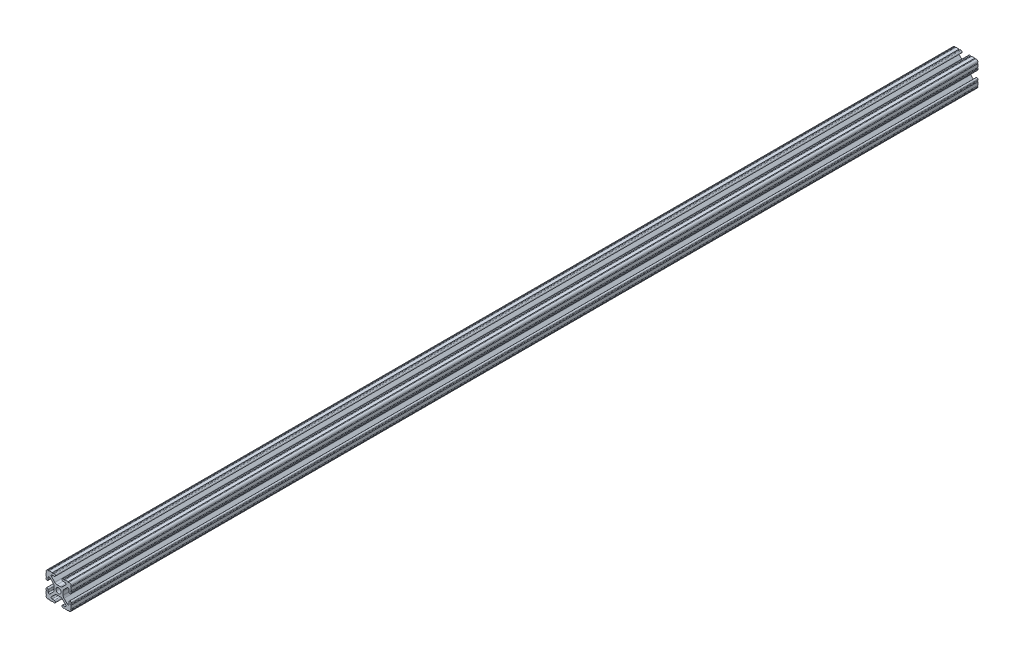
from build123d import *

# Parameters (mm, degrees)
SKETCH1_R           = 2.6035
BOSS_EXTRUDE1_DEPTH = 914.4


with BuildPart() as part:
    # Sketch1 → Boss-Extrude1 (new body)
    with BuildSketch(Plane.XY):
        with BuildLine():
            Line((-12.7, -6.3330836), (-12.7, -9.5504))
            ThreePointArc((-12.7, -9.5504), (-12.192000006, -10.058323491), (-12.699846982, -10.566399977))
            ThreePointArc((-12.699846982, -10.566399977), (-12.082522516, -12.082522516), (-10.566399977, -12.699846982))
            ThreePointArc((-10.566399977, -12.699846982), (-10.058323491, -12.192000006), (-9.5504, -12.7))
            Line((-9.5504, -12.7), (-6.3330836, -12.7))
            ThreePointArc((-6.3330836, -12.7), (-5.8250836, -12.192), (-5.3170836, -12.7))
            Line((-5.3170836, -12.7), (-4.343399971, -12.7))
            ThreePointArc((-4.343399971, -12.7), (-3.238499971, -11.5951), (-4.343399971, -10.4902))
            Line((-4.343399971, -10.4902), (-6.474794456, -10.4902))
            ThreePointArc((-6.474794456, -10.4902), (-7.413456061, -9.863006367), (-7.193214945, -8.75577951))
            Line((-7.193214945, -8.75577951), (-3.863171405, -5.42573597))
            ThreePointArc((-3.863171405, -5.42573597), (-2.833127272, -4.737482484), (-1.618107374, -4.4958))
            Line((-1.618107374, -4.4958), (1.618107374, -4.4958))
            ThreePointArc((1.618107374, -4.4958), (2.833127272, -4.737482484), (3.863171405, -5.42573597))
            Line((3.863171405, -5.42573597), (7.193214945, -8.75577951))
            ThreePointArc((7.193214945, -8.75577951), (7.413456061, -9.863006367), (6.474794456, -10.4902))
            Line((6.474794456, -10.4902), (4.3434, -10.4902))
            ThreePointArc((4.3434, -10.4902), (3.2385, -11.5951), (4.3434, -12.7))
            Line((4.3434, -12.7), (5.3170836, -12.7))
            ThreePointArc((5.3170836, -12.7), (5.8250836, -12.192), (6.3330836, -12.7))
            Line((6.3330836, -12.7), (9.5504, -12.7))
            ThreePointArc((9.5504, -12.7), (10.058323491, -12.192000006), (10.566399977, -12.699846982))
            ThreePointArc((10.566399977, -12.699846982), (12.082522516, -12.082522516), (12.699846982, -10.566399977))
            ThreePointArc((12.699846982, -10.566399977), (12.192000006, -10.058323491), (12.7, -9.5504))
            Line((12.7, -9.5504), (12.7, -6.3330836))
            ThreePointArc((12.7, -6.3330836), (12.192, -5.8250836), (12.7, -5.3170836))
            Line((12.7, -5.3170836), (12.7, -4.343399971))
            ThreePointArc((12.7, -4.343399971), (11.5951, -3.238499971), (10.4902, -4.343399971))
            Line((10.4902, -4.343399971), (10.4902, -6.474794456))
            ThreePointArc((10.4902, -6.474794456), (9.863006367, -7.413456061), (8.75577951, -7.193214945))
            Line((8.75577951, -7.193214945), (5.42573597, -3.863171405))
            ThreePointArc((5.42573597, -3.863171405), (4.737482484, -2.833127272), (4.4958, -1.618107374))
            Line((4.4958, -1.618107374), (4.4958, 1.618107374))
            ThreePointArc((4.4958, 1.618107374), (4.737482484, 2.833127272), (5.42573597, 3.863171405))
            Line((5.42573597, 3.863171405), (8.75577951, 7.193214945))
            ThreePointArc((8.75577951, 7.193214945), (9.863006367, 7.413456061), (10.4902, 6.474794456))
            Line((10.4902, 6.474794456), (10.4902, 4.3434))
            ThreePointArc((10.4902, 4.3434), (11.5951, 3.2385), (12.7, 4.3434))
            Line((12.7, 4.3434), (12.7, 5.3170836))
            ThreePointArc((12.7, 5.3170836), (12.192, 5.8250836), (12.7, 6.3330836))
            Line((12.7, 6.3330836), (12.7, 9.5504))
            ThreePointArc((12.7, 9.5504), (12.192000006, 10.058323491), (12.699846982, 10.566399977))
            ThreePointArc((12.699846982, 10.566399977), (12.082522516, 12.082522516), (10.566399977, 12.699846982))
            ThreePointArc((10.566399977, 12.699846982), (10.058323491, 12.192000006), (9.5504, 12.7))
            Line((9.5504, 12.7), (6.3330836, 12.7))
            ThreePointArc((6.3330836, 12.7), (5.8250836, 12.192), (5.3170836, 12.7))
            Line((5.3170836, 12.7), (4.343399971, 12.7))
            ThreePointArc((4.343399971, 12.7), (3.238499971, 11.5951), (4.343399971, 10.4902))
            Line((4.343399971, 10.4902), (6.474794456, 10.4902))
            ThreePointArc((6.474794456, 10.4902), (7.413456061, 9.863006367), (7.193214945, 8.75577951))
            Line((7.193214945, 8.75577951), (3.863171405, 5.42573597))
            ThreePointArc((3.863171405, 5.42573597), (2.833127272, 4.737482484), (1.618107374, 4.4958))
            Line((1.618107374, 4.4958), (-1.618107374, 4.4958))
            ThreePointArc((-1.618107374, 4.4958), (-2.833127272, 4.737482484), (-3.863171405, 5.42573597))
            Line((-3.863171405, 5.42573597), (-7.193214945, 8.75577951))
            ThreePointArc((-7.193214945, 8.75577951), (-7.413456061, 9.863006367), (-6.474794456, 10.4902))
            Line((-6.474794456, 10.4902), (-4.3434, 10.4902))
            ThreePointArc((-4.3434, 10.4902), (-3.2385, 11.5951), (-4.3434, 12.7))
            Line((-4.3434, 12.7), (-5.3170836, 12.7))
            ThreePointArc((-5.3170836, 12.7), (-5.8250836, 12.192), (-6.3330836, 12.7))
            Line((-6.3330836, 12.7), (-9.5504, 12.7))
            ThreePointArc((-9.5504, 12.7), (-10.058323491, 12.192000006), (-10.566399977, 12.699846982))
            ThreePointArc((-10.566399977, 12.699846982), (-12.082522516, 12.082522516), (-12.699846982, 10.566399977))
            ThreePointArc((-12.699846982, 10.566399977), (-12.192000006, 10.058323491), (-12.7, 9.5504))
            Line((-12.7, 9.5504), (-12.7, 6.3330836))
            ThreePointArc((-12.7, 6.3330836), (-12.192, 5.8250836), (-12.7, 5.3170836))
            Line((-12.7, 5.3170836), (-12.7, 4.343399971))
            ThreePointArc((-12.7, 4.343399971), (-11.5951, 3.238499971), (-10.4902, 4.343399971))
            Line((-10.4902, 4.343399971), (-10.4902, 6.474794456))
            ThreePointArc((-10.4902, 6.474794456), (-9.863006367, 7.413456061), (-8.75577951, 7.193214945))
            Line((-8.75577951, 7.193214945), (-5.42573597, 3.863171405))
            ThreePointArc((-5.42573597, 3.863171405), (-4.737482484, 2.833127272), (-4.4958, 1.618107374))
            Line((-4.4958, 1.618107374), (-4.4958, -1.618107374))
            ThreePointArc((-4.4958, -1.618107374), (-4.737482484, -2.833127272), (-5.42573597, -3.863171405))
            Line((-5.42573597, -3.863171405), (-8.75577951, -7.193214945))
            ThreePointArc((-8.75577951, -7.193214945), (-9.863006367, -7.413456061), (-10.4902, -6.474794456))
            Line((-10.4902, -6.474794456), (-10.4902, -4.3434))
            ThreePointArc((-10.4902, -4.3434), (-11.5951, -3.2385), (-12.7, -4.3434))
            Line((-12.7, -4.3434), (-12.7, -5.3170836))
            ThreePointArc((-12.7, -5.3170836), (-12.192, -5.8250836), (-12.7, -6.3330836))
        make_face()
        Circle(SKETCH1_R, mode=Mode.SUBTRACT)
    extrude(amount=-BOSS_EXTRUDE1_DEPTH)


solid = part.part
